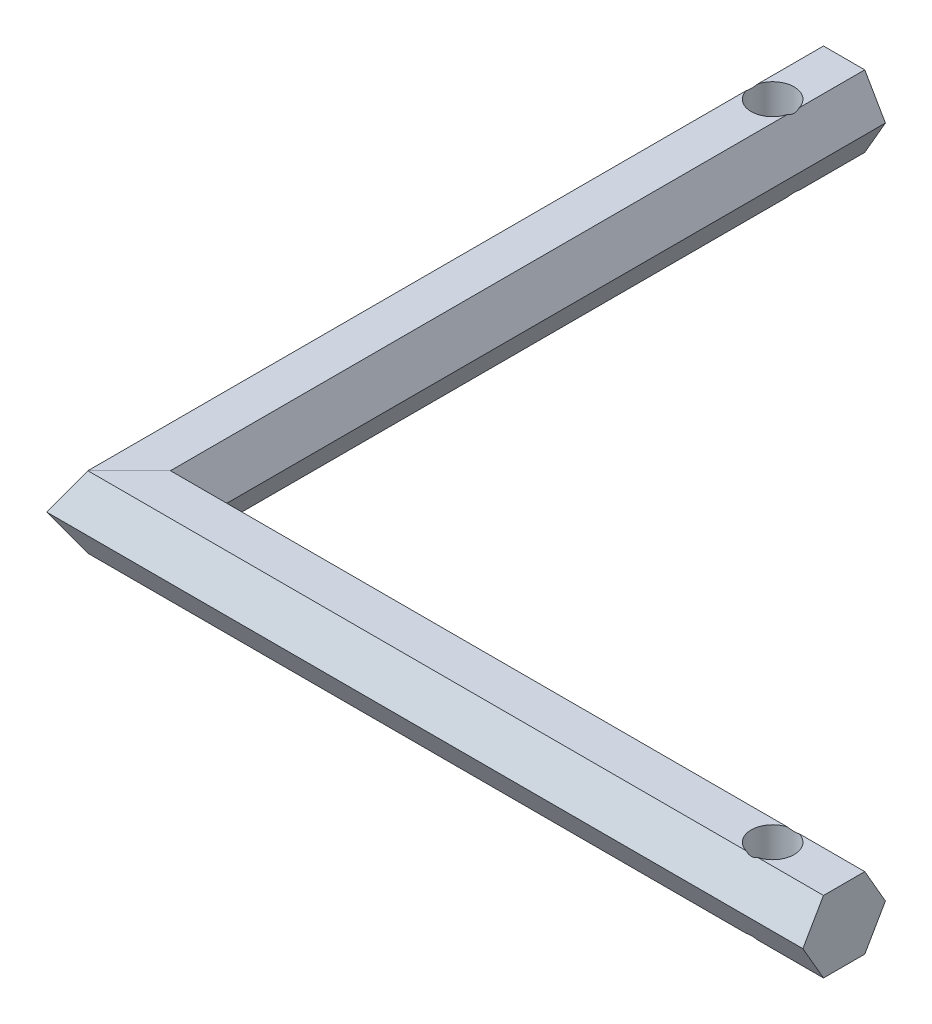
from build123d import *

# Parameters (mm, degrees)
SKETCH3_R               = 3
CUT_EXTRUDE1_DEPTH      = 6
CUT_EXTRUDE1_DEPTH_BACK = 6


with BuildPart() as part:
    # Sweep1: sweep along a path in Sketch1
    with BuildLine(Plane(origin=(0, 0, 0), x_dir=(1, 0, 0), z_dir=(0, 1, 0))) as sweep1_path:
        Line((0, 100), (0, 0))
        Line((0, 0), (100, 0))
    # Sketch2 → Sweep1 (sweep)
    with BuildSketch(Plane.XY.offset(-100)):
        Polygon((5.773502692, 0), (2.886751346, 5), (-2.886751346, 5), (-5.773502692, 0), (-2.886751346, -5), (2.886751346, -5), align=None)
    sweep(path=sweep1_path.line, transition=Transition.RIGHT)

    # Sketch3 → Cut-Extrude1 (cut, two sides)
    with BuildSketch(Plane(origin=(0, 0, 0), x_dir=(1, 0, 0), z_dir=(0, 1, 0))) as cut_extrude1_sk:
        with Locations((0, 90)):
            Circle(SKETCH3_R)
        with Locations((90, 0)):
            Circle(SKETCH3_R)
    extrude(amount=CUT_EXTRUDE1_DEPTH, mode=Mode.SUBTRACT)
    extrude(cut_extrude1_sk.sketch, amount=-CUT_EXTRUDE1_DEPTH_BACK, mode=Mode.SUBTRACT)


solid = part.part
